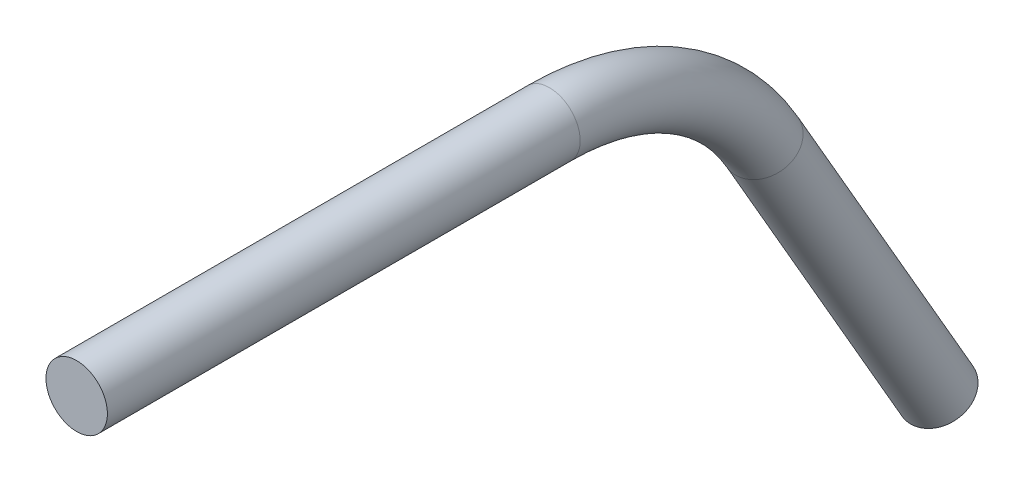
from build123d import *

# Parameters (mm, degrees)
SKETCH2_R = 3.175


with BuildPart() as part:
    # Sweep1: sweep along a path in Sketch4
    with BuildLine(Plane(origin=(0, 0, 0), x_dir=(0, 0, -1), z_dir=(1, 0, 0))) as sweep1_path:
        Line((0, 0), (48.835303163, 0))
        ThreePointArc((48.835303163, 0), (61.535303163, -3.402954744), (70.832348419, -12.7))
        Line((70.832348419, -12.7), (88.9, -43.994090512))
    # Sketch2 → Sweep1 (sweep)
    with BuildSketch(Plane.XY):
        Circle(SKETCH2_R)
    sweep(path=sweep1_path.line)


solid = part.part
